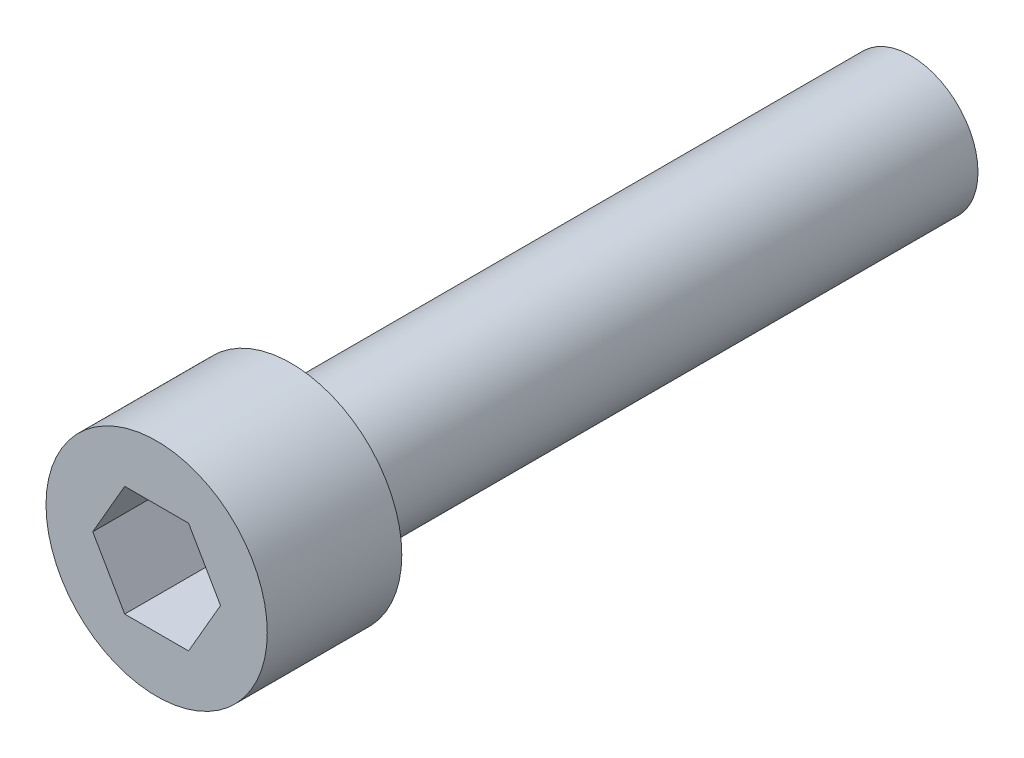
from build123d import *

# Parameters (mm, degrees)
SKETCH1_R           = 2.413
BOSS_EXTRUDE1_DEPTH = 22.225
SKETCH2_R           = 3.96875
BOSS_EXTRUDE2_DEPTH = 4.826
CUT_EXTRUDE1_DEPTH  = 3.81


with BuildPart() as part:
    # Sketch1 → Boss-Extrude1 (new body)
    with BuildSketch(Plane.XY):
        Circle(SKETCH1_R)
    extrude(amount=BOSS_EXTRUDE1_DEPTH)

    # Sketch2 → Boss-Extrude2 (add)
    with BuildSketch(Plane.XY.offset(22.225)):
        Circle(SKETCH2_R)
    extrude(amount=BOSS_EXTRUDE2_DEPTH)

    # Sketch3 → Cut-Extrude1 (cut)
    with BuildSketch(Plane.XY.offset(27.051)):
        Polygon((2.291358881, 0), (1.14567944, 1.984375), (-1.14567944, 1.984375), (-2.291358881, 0), (-1.14567944, -1.984375), (1.14567944, -1.984375), align=None)
    extrude(amount=-CUT_EXTRUDE1_DEPTH, mode=Mode.SUBTRACT)


solid = part.part
